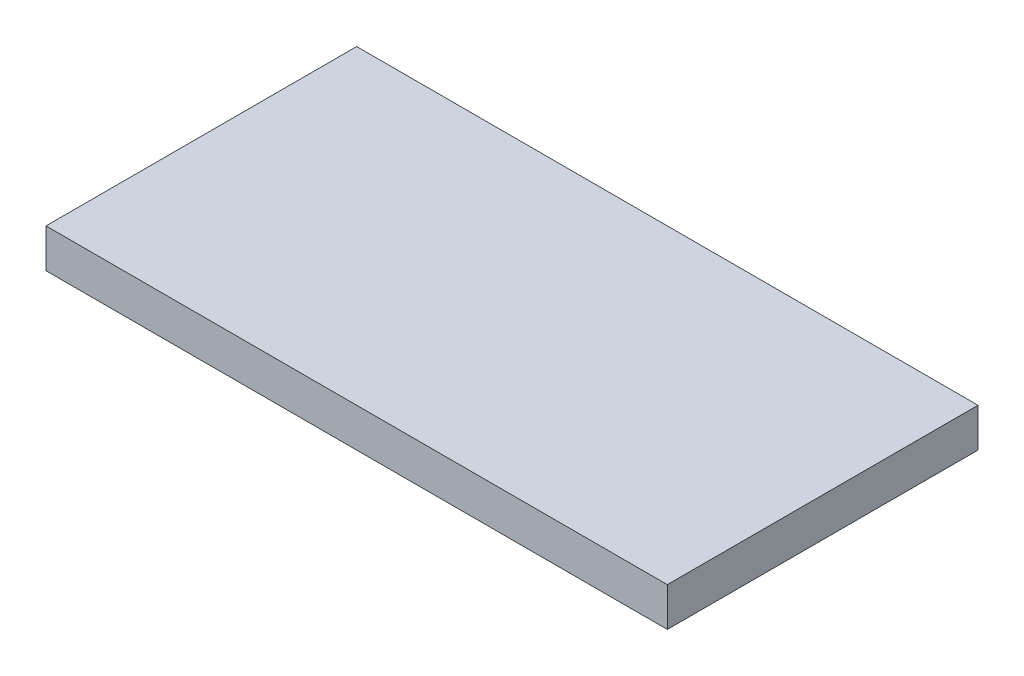
from build123d import *

# Parameters (mm, degrees)
SKETCH1_W           = 406.4
SKETCH1_H           = 203.2
BOSS_EXTRUDE1_DEPTH = 12.7


with BuildPart() as part:
    # Sketch1 → Boss-Extrude1 (new body, symmetric)
    with BuildSketch(Plane(origin=(0, 0, 0), x_dir=(1, 0, 0), z_dir=(0, 1, 0))):
        Rectangle(SKETCH1_W, SKETCH1_H)
    extrude(amount=BOSS_EXTRUDE1_DEPTH, both=True)


solid = part.part
